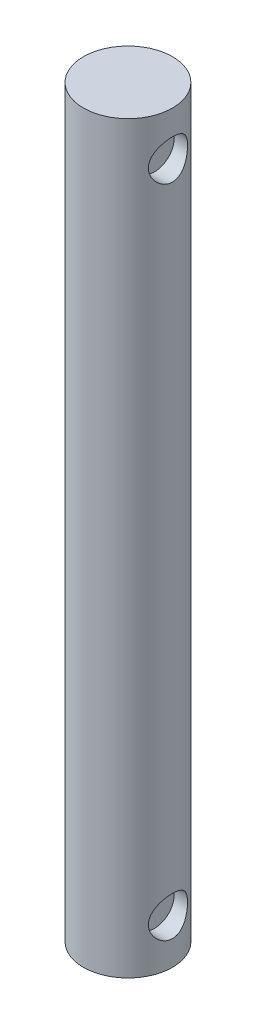
from build123d import *

# Parameters (mm, degrees)
SKETCH_1_R          = 2.5
EXTRUDE_1_DEPTH     = 41.8
SKETCH_6_R          = 1.1
CUT_EXTRUDE_1_DEPTH = 1


with BuildPart() as part:
    # 草图1 → 凸台-拉伸1 (new body)
    with BuildSketch(Plane(origin=(0, 0, 0), x_dir=(1, 0, 0), z_dir=(0, 1, 0))):
        Circle(SKETCH_1_R)
    extrude(amount=EXTRUDE_1_DEPTH)

    # 草图6 → 切除-拉伸1 (cut)
    with BuildSketch(Plane(origin=(2.5, 0, 0), x_dir=(0, 0, -1), z_dir=(1, 0, 0))):
        with Locations((0, 39.3)):
            Circle(SKETCH_6_R)
        with Locations((0, 2.5)):
            Circle(SKETCH_6_R)
    extrude(amount=-CUT_EXTRUDE_1_DEPTH, mode=Mode.SUBTRACT)


solid = part.part
